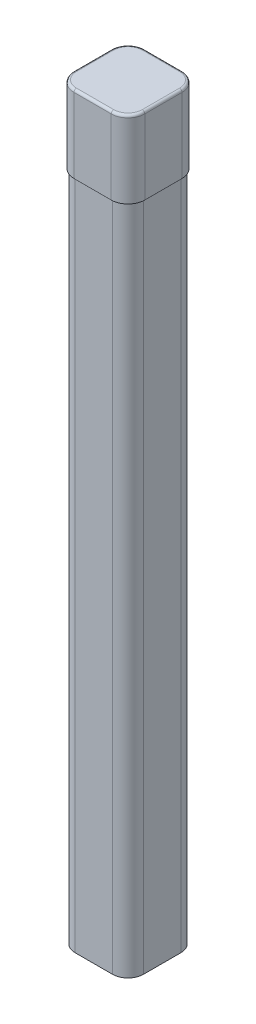
from build123d import *

# Parameters (mm, degrees)
BOSS_EXTRUDE1_DEPTH = 152.4
BOSS_EXTRUDE2_DEPTH = 15.24
BOSS_EXTRUDE3_DEPTH = 0.508
FILLET1_R           = 0.508


with BuildPart() as part:
    # Sketch1 → Boss-Extrude1 (new body)
    with BuildSketch(Plane(origin=(0, 0, 0), x_dir=(1, 0, 0), z_dir=(0, 1, 0))):
        with BuildLine():
            Line((3.81, -6.985), (-3.81, -6.985))
            ThreePointArc((-3.81, -6.985), (-6.05506403, -6.05506403), (-6.985, -3.81))
            Line((-6.985, -3.81), (-6.985, 3.81))
            ThreePointArc((-6.985, 3.81), (-6.05506403, 6.05506403), (-3.81, 6.985))
            Line((-3.81, 6.985), (3.81, 6.985))
            ThreePointArc((3.81, 6.985), (6.05506403, 6.05506403), (6.985, 3.81))
            Line((6.985, 3.81), (6.985, -3.81))
            ThreePointArc((6.985, -3.81), (6.05506403, -6.05506403), (3.81, -6.985))
        make_face()
        with BuildLine():
            Line((3.81, 6.731), (-3.81, 6.731))
            ThreePointArc((-3.81, 6.731), (-5.875458908, 5.875458908), (-6.731, 3.81))
            Line((-6.731, 3.81), (-6.731, -3.81))
            ThreePointArc((-6.731, -3.81), (-5.875458908, -5.875458908), (-3.81, -6.731))
            Line((-3.81, -6.731), (3.81, -6.731))
            ThreePointArc((3.81, -6.731), (5.875458908, -5.875458908), (6.731, -3.81))
            Line((6.731, -3.81), (6.731, 3.81))
            ThreePointArc((6.731, 3.81), (5.875458908, 5.875458908), (3.81, 6.731))
        make_face(mode=Mode.SUBTRACT)
    extrude(amount=BOSS_EXTRUDE1_DEPTH)


with BuildPart() as body_2:
    # Sketch2 → Boss-Extrude2 (new body)
    with BuildSketch(Plane(origin=(0, 152.4, 0), x_dir=(1, 0, 0), z_dir=(0, 1, 0))):
        with BuildLine():
            Line((-7.239, 3.81), (-7.239, -3.81))
            ThreePointArc((-7.239, -3.81), (-6.234669153, -6.234669153), (-3.81, -7.239))
            Line((-3.81, -7.239), (3.81, -7.239))
            ThreePointArc((3.81, -7.239), (6.234669153, -6.234669153), (7.239, -3.81))
            Line((7.239, -3.81), (7.239, 3.81))
            ThreePointArc((7.239, 3.81), (6.234669153, 6.234669153), (3.81, 7.239))
            Line((3.81, 7.239), (-3.81, 7.239))
            ThreePointArc((-3.81, 7.239), (-6.234669153, 6.234669153), (-7.239, 3.81))
        make_face()
        with BuildLine():
            Line((-3.81, -6.985), (3.81, -6.985))
            ThreePointArc((3.81, -6.985), (6.05506403, -6.05506403), (6.985, -3.81))
            Line((6.985, -3.81), (6.985, 3.81))
            ThreePointArc((6.985, 3.81), (6.05506403, 6.05506403), (3.81, 6.985))
            Line((3.81, 6.985), (-3.81, 6.985))
            ThreePointArc((-3.81, 6.985), (-6.05506403, 6.05506403), (-6.985, 3.81))
            Line((-6.985, 3.81), (-6.985, -3.81))
            ThreePointArc((-6.985, -3.81), (-6.05506403, -6.05506403), (-3.81, -6.985))
        make_face(mode=Mode.SUBTRACT)
    extrude(amount=-BOSS_EXTRUDE2_DEPTH)

    # Sketch3 → Boss-Extrude3 (add)
    with BuildSketch(Plane(origin=(0, 152.4, 0), x_dir=(1, 0, 0), z_dir=(0, 1, 0))):
        with BuildLine():
            Line((-7.239, 3.81), (-7.239, -3.81))
            ThreePointArc((-7.239, -3.81), (-6.234669153, -6.234669153), (-3.81, -7.239))
            Line((-3.81, -7.239), (3.81, -7.239))
            ThreePointArc((3.81, -7.239), (6.234669153, -6.234669153), (7.239, -3.81))
            Line((7.239, -3.81), (7.239, 3.81))
            ThreePointArc((7.239, 3.81), (6.234669153, 6.234669153), (3.81, 7.239))
            Line((3.81, 7.239), (-3.81, 7.239))
            ThreePointArc((-3.81, 7.239), (-6.234669153, 6.234669153), (-7.239, 3.81))
        make_face()
    extrude(amount=BOSS_EXTRUDE3_DEPTH)

    # Fillet1
    fillet1_edges = [body_2.edges().sort_by_distance(p)[0] for p in [
        (-6.234669153, 152.908, -6.234669153),
        (-7.239, 152.908, 0),
        (-6.234669153, 152.908, 6.234669153),
        (0, 152.908, 7.239),
        (6.234669153, 152.908, 6.234669153),
        (7.239, 152.908, 0),
        (6.234669153, 152.908, -6.234669153),
        (0, 152.908, -7.239),
    ]]
    fillet(fillet1_edges, radius=FILLET1_R)


solid = Compound([part.part, body_2.part])
